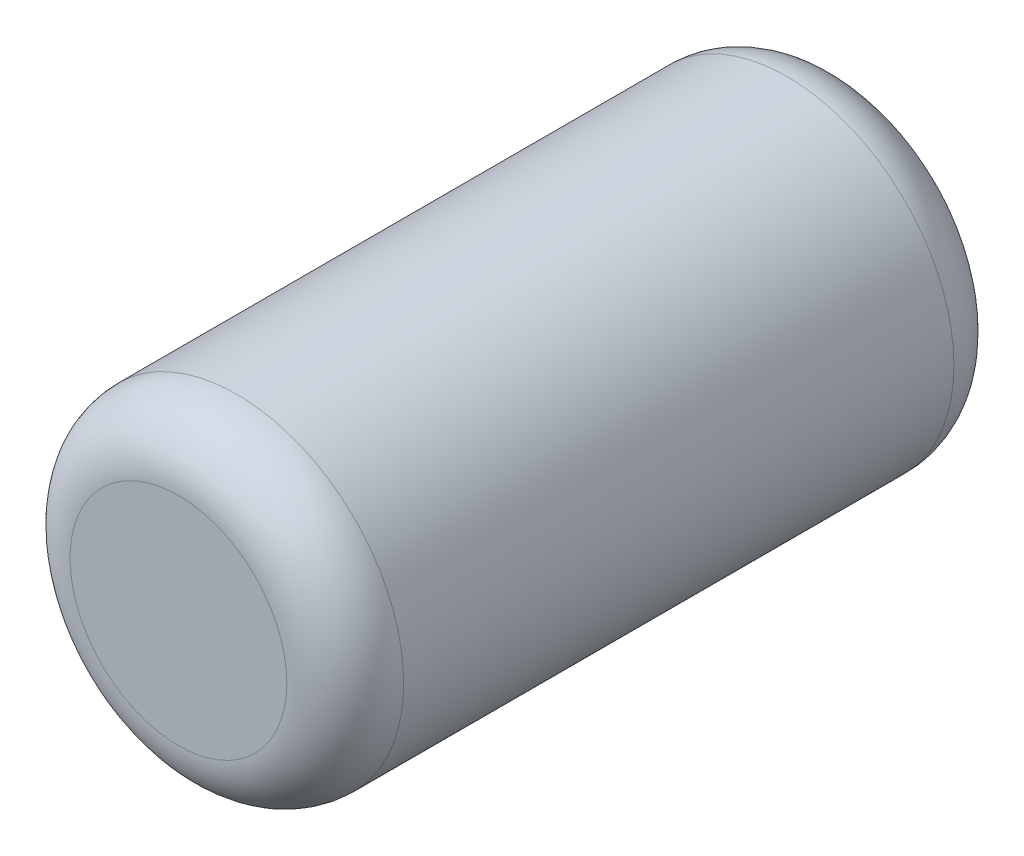
from build123d import *

# Parameters (mm, degrees)
SKETCH1_R           = 1
BOSS_EXTRUDE1_DEPTH = 2
FILLET1_R           = 0.35


with BuildPart() as part:
    # Sketch1 → Boss-Extrude1 (new body, symmetric)
    with BuildSketch(Plane.XY):
        Circle(SKETCH1_R)
    extrude(amount=BOSS_EXTRUDE1_DEPTH, both=True)

    # Fillet1
    fillet1_edges = [part.edges().sort_by_distance(p)[0] for p in [
        (-1, 0, -2),
        (-1, 0, 2),
    ]]
    fillet(fillet1_edges, radius=FILLET1_R)


solid = part.part
